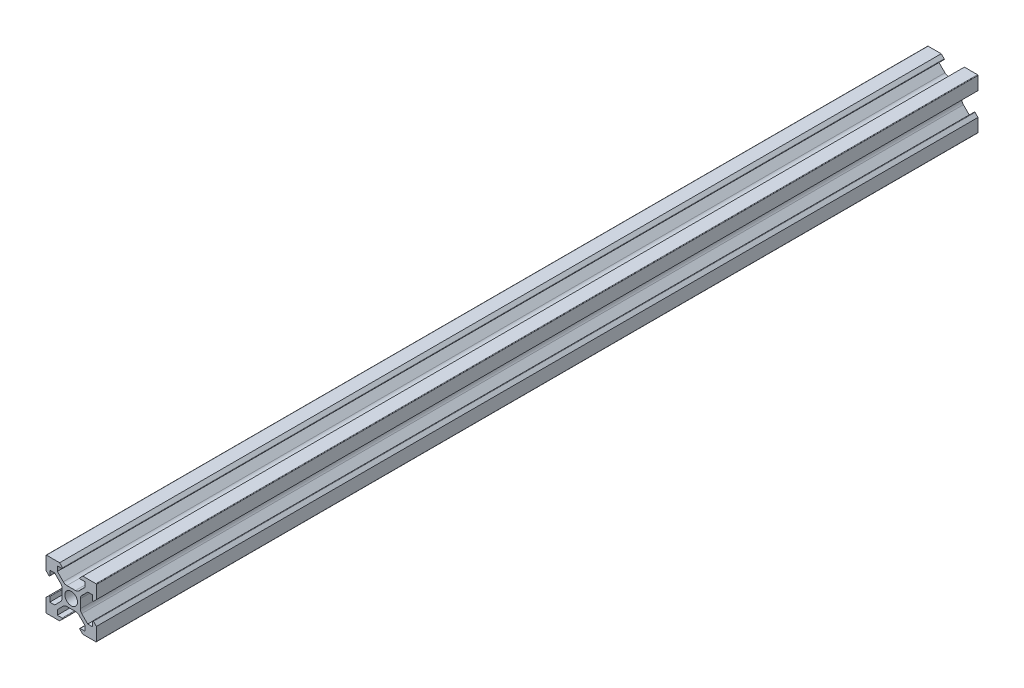
from build123d import *

# Parameters (mm, degrees)
ESBO_O1_R                = 2.5
RESSALTO_EXTRUS_O1_DEPTH = 350


with BuildPart() as part:
    # Esboço1 → Ressalto-extrusão1 (new body)
    with BuildSketch(Plane.XY):
        with BuildLine():
            Line((-4.6, -10), (-9.8, -10))
            ThreePointArc((-9.8, -10), (-9.941421356, -9.941421356), (-10, -9.8))
            Line((-10, -9.8), (-10, -4.6))
            Line((-10, -4.6), (-8.841421356, -3.441421356))
            ThreePointArc((-8.841421356, -3.441421356), (-8.623463314, -3.398066806), (-8.5, -3.582842712))
            Line((-8.5, -3.582842712), (-8.5, -5.5))
            Line((-8.5, -5.5), (-6.560660172, -5.5))
            Line((-6.560660172, -5.5), (-4.185786438, -3.125126266))
            ThreePointArc((-4.185786438, -3.125126266), (-3.752240935, -2.476279568), (-3.6, -1.710912703))
            Line((-3.6, -1.710912703), (-3.6, 1.710912703))
            ThreePointArc((-3.6, 1.710912703), (-3.752240935, 2.476279568), (-4.185786438, 3.125126266))
            Line((-4.185786438, 3.125126266), (-6.560660172, 5.5))
            Line((-6.560660172, 5.5), (-8.5, 5.5))
            Line((-8.5, 5.5), (-8.5, 3.582842712))
            ThreePointArc((-8.5, 3.582842712), (-8.623463314, 3.398066806), (-8.841421356, 3.441421356))
            Line((-8.841421356, 3.441421356), (-10, 4.6))
            Line((-10, 4.6), (-10, 9.8))
            ThreePointArc((-10, 9.8), (-9.941421356, 9.941421356), (-9.8, 10))
            Line((-9.8, 10), (-4.6, 10))
            Line((-4.6, 10), (-3.441421356, 8.841421356))
            ThreePointArc((-3.441421356, 8.841421356), (-3.398066806, 8.623463314), (-3.582842712, 8.5))
            Line((-3.582842712, 8.5), (-5.5, 8.5))
            Line((-5.5, 8.5), (-5.5, 6.560660172))
            Line((-5.5, 6.560660172), (-3.125126266, 4.185786438))
            ThreePointArc((-3.125126266, 4.185786438), (-2.476279568, 3.752240935), (-1.710912703, 3.6))
            Line((-1.710912703, 3.6), (1.710912703, 3.6))
            ThreePointArc((1.710912703, 3.6), (2.476279568, 3.752240935), (3.125126266, 4.185786438))
            Line((3.125126266, 4.185786438), (5.5, 6.560660172))
            Line((5.5, 6.560660172), (5.5, 8.5))
            Line((5.5, 8.5), (3.582842712, 8.5))
            ThreePointArc((3.582842712, 8.5), (3.398066806, 8.623463314), (3.441421356, 8.841421356))
            Line((3.441421356, 8.841421356), (4.6, 10))
            Line((4.6, 10), (9.8, 10))
            ThreePointArc((9.8, 10), (9.941421356, 9.941421356), (10, 9.8))
            Line((10, 9.8), (10, 4.6))
            Line((10, 4.6), (8.841421356, 3.441421356))
            ThreePointArc((8.841421356, 3.441421356), (8.623463314, 3.398066806), (8.5, 3.582842712))
            Line((8.5, 3.582842712), (8.5, 5.5))
            Line((8.5, 5.5), (6.560660172, 5.5))
            Line((6.560660172, 5.5), (4.185786438, 3.125126266))
            ThreePointArc((4.185786438, 3.125126266), (3.752240935, 2.476279568), (3.6, 1.710912703))
            Line((3.6, 1.710912703), (3.6, -1.710912703))
            ThreePointArc((3.6, -1.710912703), (3.752240935, -2.476279568), (4.185786438, -3.125126266))
            Line((4.185786438, -3.125126266), (6.560660172, -5.5))
            Line((6.560660172, -5.5), (8.5, -5.5))
            Line((8.5, -5.5), (8.5, -3.582842712))
            ThreePointArc((8.5, -3.582842712), (8.623463314, -3.398066806), (8.841421356, -3.441421356))
            Line((8.841421356, -3.441421356), (10, -4.6))
            Line((10, -4.6), (10, -9.8))
            ThreePointArc((10, -9.8), (9.941421356, -9.941421356), (9.8, -10))
            Line((9.8, -10), (4.6, -10))
            Line((4.6, -10), (3.441421356, -8.841421356))
            ThreePointArc((3.441421356, -8.841421356), (3.398066806, -8.623463314), (3.582842712, -8.5))
            Line((3.582842712, -8.5), (5.5, -8.5))
            Line((5.5, -8.5), (5.5, -6.560660172))
            Line((5.5, -6.560660172), (3.125126266, -4.185786438))
            ThreePointArc((3.125126266, -4.185786438), (2.476279568, -3.752240935), (1.710912703, -3.6))
            Line((1.710912703, -3.6), (-1.710912703, -3.6))
            ThreePointArc((-1.710912703, -3.6), (-2.476279568, -3.752240935), (-3.125126266, -4.185786438))
            Line((-3.125126266, -4.185786438), (-5.5, -6.560660172))
            Line((-5.5, -6.560660172), (-5.5, -8.5))
            Line((-5.5, -8.5), (-3.582842712, -8.5))
            ThreePointArc((-3.582842712, -8.5), (-3.398066806, -8.623463314), (-3.441421356, -8.841421356))
            Line((-3.441421356, -8.841421356), (-4.6, -10))
        make_face()
        Circle(ESBO_O1_R, mode=Mode.SUBTRACT)
    extrude(amount=RESSALTO_EXTRUS_O1_DEPTH)


solid = part.part
